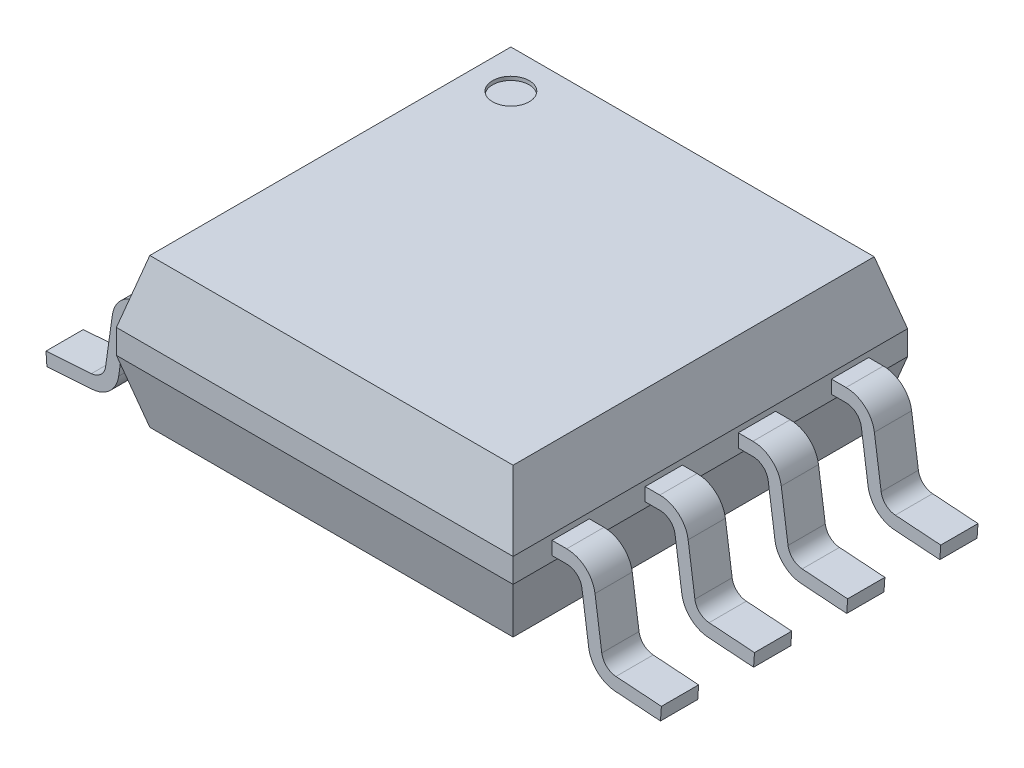
from build123d import *
from OCP.BRepFilletAPI import BRepFilletAPI_MakeChamfer

# Parameters (mm, degrees)
SKETCH1_W              = 5.41
SKETCH1_H              = 5.38
BASE_EXTRUDE_DEPTH     = 2.03
PIN_1_DEPTH            = 0.254
LPATTERN1_COUNT        = 4
LPATTERN1_PITCH        = 1.27
LPATTERN1_COPY_1_DEPTH = 0.254
LPATTERN1_COPY_2_DEPTH = 0.254
LPATTERN1_COPY_3_DEPTH = 0.254
TOP_CHAMFER_SIZE       = 0.85
TOP_CHAMFER_SIZE2      = 0.227756814
BOTTOM_CHAMFER_SIZE    = 0.85
BOTTOM_CHAMFER_SIZE2   = 0.227756814
SKETCH3_R              = 0.25
PIN1_HOL_DEPTH         = 0.05


with BuildPart() as part:
    # Sketch1 → Base-Extrude (new body)
    with BuildSketch(Plane(origin=(0, 0, 0), x_dir=(1, 0, 0), z_dir=(0, 1, 0))):
        Rectangle(SKETCH1_W, SKETCH1_H)
    extrude(amount=-BASE_EXTRUDE_DEPTH)

    # Sketch2 → PIN 1 (add, symmetric)
    with BuildSketch(Plane.XY.offset(-1.905)):
        with BuildLine():
            Line((-2.705, -0.925), (-2.905, -0.925))
            ThreePointArc((-2.905, -0.925), (-3.160863021, -1.020663264), (-3.291204547, -1.260722491))
            Line((-3.291204547, -1.260722491), (-3.38338656, -1.916631596))
            ThreePointArc((-3.38338656, -1.916631596), (-3.448123199, -2.040989522), (-3.576693995, -2.096893695))
            Line((-3.576693995, -2.096893695), (-4.196278083, -2.140219235))
            Line((-4.196278083, -2.140219235), (-4.183721917, -2.319780765))
            Line((-4.183721917, -2.319780765), (-3.56413783, -2.276455225))
            ThreePointArc((-3.56413783, -2.276455225), (-3.325363494, -2.172633189), (-3.205138308, -1.941682754))
            Line((-3.205138308, -1.941682754), (-3.112956294, -1.285773649))
            ThreePointArc((-3.112956294, -1.285773649), (-3.042772396, -1.156510988), (-2.905, -1.105))
            Line((-2.905, -1.105), (-2.705, -1.105))
            Line((-2.705, -1.105), (-2.705, -0.925))
        make_face()
    pin_1 = extrude(amount=PIN_1_DEPTH, both=True)

    # PIN 8: PIN 1 across plane
    add(pin_1.mirror(Plane(origin=(0, 0, 0), x_dir=(0, 0, 1), z_dir=(1, 0, 0))))

    # LPattern1: PIN 1 ×4
    with Locations(*[(0, 0, i * LPATTERN1_PITCH) for i in range(1, LPATTERN1_COUNT)]):
        add(pin_1)

    # LPattern1 copy 1 sketch → LPattern1 copy 1 (add, symmetric)
    with BuildSketch(Plane(origin=(0, 0, -0.635), x_dir=(-1, 0, 0), z_dir=(0, 0, 1))):
        with BuildLine():
            Line((-2.705, 0.925), (-2.905, 0.925))
            ThreePointArc((-2.905, 0.925), (-3.160863021, 1.020663264), (-3.291204547, 1.260722491))
            Line((-3.291204547, 1.260722491), (-3.38338656, 1.916631596))
            ThreePointArc((-3.38338656, 1.916631596), (-3.448123199, 2.040989522), (-3.576693995, 2.096893695))
            Line((-3.576693995, 2.096893695), (-4.196278083, 2.140219235))
            Line((-4.196278083, 2.140219235), (-4.183721917, 2.319780765))
            Line((-4.183721917, 2.319780765), (-3.56413783, 2.276455225))
            ThreePointArc((-3.56413783, 2.276455225), (-3.325363494, 2.172633189), (-3.205138308, 1.941682754))
            Line((-3.205138308, 1.941682754), (-3.112956294, 1.285773649))
            ThreePointArc((-3.112956294, 1.285773649), (-3.042772396, 1.156510988), (-2.905, 1.105))
            Line((-2.905, 1.105), (-2.705, 1.105))
            Line((-2.705, 1.105), (-2.705, 0.925))
        make_face()
    extrude(amount=LPATTERN1_COPY_1_DEPTH, both=True)

    # LPattern1 copy 2 sketch → LPattern1 copy 2 (add, symmetric)
    with BuildSketch(Plane(origin=(0, 0, 0.635), x_dir=(-1, 0, 0), z_dir=(0, 0, 1))):
        with BuildLine():
            Line((-2.705, 0.925), (-2.905, 0.925))
            ThreePointArc((-2.905, 0.925), (-3.160863021, 1.020663264), (-3.291204547, 1.260722491))
            Line((-3.291204547, 1.260722491), (-3.38338656, 1.916631596))
            ThreePointArc((-3.38338656, 1.916631596), (-3.448123199, 2.040989522), (-3.576693995, 2.096893695))
            Line((-3.576693995, 2.096893695), (-4.196278083, 2.140219235))
            Line((-4.196278083, 2.140219235), (-4.183721917, 2.319780765))
            Line((-4.183721917, 2.319780765), (-3.56413783, 2.276455225))
            ThreePointArc((-3.56413783, 2.276455225), (-3.325363494, 2.172633189), (-3.205138308, 1.941682754))
            Line((-3.205138308, 1.941682754), (-3.112956294, 1.285773649))
            ThreePointArc((-3.112956294, 1.285773649), (-3.042772396, 1.156510988), (-2.905, 1.105))
            Line((-2.905, 1.105), (-2.705, 1.105))
            Line((-2.705, 1.105), (-2.705, 0.925))
        make_face()
    extrude(amount=LPATTERN1_COPY_2_DEPTH, both=True)

    # LPattern1 copy 3 sketch → LPattern1 copy 3 (add, symmetric)
    with BuildSketch(Plane(origin=(0, 0, 1.905), x_dir=(-1, 0, 0), z_dir=(0, 0, 1))):
        with BuildLine():
            Line((-2.705, 0.925), (-2.905, 0.925))
            ThreePointArc((-2.905, 0.925), (-3.160863021, 1.020663264), (-3.291204547, 1.260722491))
            Line((-3.291204547, 1.260722491), (-3.38338656, 1.916631596))
            ThreePointArc((-3.38338656, 1.916631596), (-3.448123199, 2.040989522), (-3.576693995, 2.096893695))
            Line((-3.576693995, 2.096893695), (-4.196278083, 2.140219235))
            Line((-4.196278083, 2.140219235), (-4.183721917, 2.319780765))
            Line((-4.183721917, 2.319780765), (-3.56413783, 2.276455225))
            ThreePointArc((-3.56413783, 2.276455225), (-3.325363494, 2.172633189), (-3.205138308, 1.941682754))
            Line((-3.205138308, 1.941682754), (-3.112956294, 1.285773649))
            ThreePointArc((-3.112956294, 1.285773649), (-3.042772396, 1.156510988), (-2.905, 1.105))
            Line((-2.905, 1.105), (-2.705, 1.105))
            Line((-2.705, 1.105), (-2.705, 0.925))
        make_face()
    extrude(amount=LPATTERN1_COPY_3_DEPTH, both=True)

    # TOP CHAMFER: one chamfer whose edges measure the first distance from different faces: ONE call of the kernel's chamfer builder (chamfer() names one face for all edges)
    top_chamfer_edges_1 = [part.edges().sort_by_distance(p)[0] for p in [
        (0, 0, -2.69),
    ]]
    top_chamfer_side_1 = [part.faces().sort_by_distance(p)[0] for p in [
        (0, -1.015, -2.69),
    ]]
    top_chamfer_edges_2 = [part.edges().sort_by_distance(p)[0] for p in [
        (2.705, 0, 0),
    ]]
    top_chamfer_side_2 = [part.faces().sort_by_distance(p)[0] for p in [
        (2.705, -1.015, 0),
    ]]
    top_chamfer_edges_3 = [part.edges().sort_by_distance(p)[0] for p in [
        (0, 0, 2.69),
    ]]
    top_chamfer_side_3 = [part.faces().sort_by_distance(p)[0] for p in [
        (0, -1.015, 2.69),
    ]]
    top_chamfer_edges_4 = [part.edges().sort_by_distance(p)[0] for p in [
        (-2.705, 0, 0),
    ]]
    top_chamfer_side_4 = [part.faces().sort_by_distance(p)[0] for p in [
        (-2.705, -1.015, 0),
    ]]
    top_chamfer = BRepFilletAPI_MakeChamfer(part.part.solid().wrapped)
    for e in top_chamfer_edges_1:
        top_chamfer.Add(TOP_CHAMFER_SIZE, TOP_CHAMFER_SIZE2, e.wrapped, top_chamfer_side_1[0].wrapped)  # the first distance lies on this face
    for e in top_chamfer_edges_2:
        top_chamfer.Add(TOP_CHAMFER_SIZE, TOP_CHAMFER_SIZE2, e.wrapped, top_chamfer_side_2[0].wrapped)  # the first distance lies on this face
    for e in top_chamfer_edges_3:
        top_chamfer.Add(TOP_CHAMFER_SIZE, TOP_CHAMFER_SIZE2, e.wrapped, top_chamfer_side_3[0].wrapped)  # the first distance lies on this face
    for e in top_chamfer_edges_4:
        top_chamfer.Add(TOP_CHAMFER_SIZE, TOP_CHAMFER_SIZE2, e.wrapped, top_chamfer_side_4[0].wrapped)  # the first distance lies on this face
    add(Compound.cast(top_chamfer.Shape()), mode=Mode.REPLACE)

    # BOTTOM CHAMFER: one chamfer whose edges measure the first distance from different faces: ONE call of the kernel's chamfer builder (chamfer() names one face for all edges)
    bottom_chamfer_edges_1 = [part.edges().sort_by_distance(p)[0] for p in [
        (2.705, -2.03, 0),
    ]]
    bottom_chamfer_side_1 = [part.faces().sort_by_distance(p)[0] for p in [
        (2.705, -1.465983178, 0),
    ]]
    bottom_chamfer_edges_2 = [part.edges().sort_by_distance(p)[0] for p in [
        (0, -2.03, -2.69),
    ]]
    bottom_chamfer_side_2 = [part.faces().sort_by_distance(p)[0] for p in [
        (0, -1.44, -2.69),
    ]]
    bottom_chamfer_edges_3 = [part.edges().sort_by_distance(p)[0] for p in [
        (-2.705, -2.03, 0),
    ]]
    bottom_chamfer_side_3 = [part.faces().sort_by_distance(p)[0] for p in [
        (-2.705, -1.465983178, 0),
    ]]
    bottom_chamfer_edges_4 = [part.edges().sort_by_distance(p)[0] for p in [
        (0, -2.03, 2.69),
    ]]
    bottom_chamfer_side_4 = [part.faces().sort_by_distance(p)[0] for p in [
        (0, -1.44, 2.69),
    ]]
    bottom_chamfer = BRepFilletAPI_MakeChamfer(part.part.solid().wrapped)
    for e in bottom_chamfer_edges_1:
        bottom_chamfer.Add(BOTTOM_CHAMFER_SIZE, BOTTOM_CHAMFER_SIZE2, e.wrapped, bottom_chamfer_side_1[0].wrapped)  # the first distance lies on this face
    for e in bottom_chamfer_edges_2:
        bottom_chamfer.Add(BOTTOM_CHAMFER_SIZE, BOTTOM_CHAMFER_SIZE2, e.wrapped, bottom_chamfer_side_2[0].wrapped)  # the first distance lies on this face
    for e in bottom_chamfer_edges_3:
        bottom_chamfer.Add(BOTTOM_CHAMFER_SIZE, BOTTOM_CHAMFER_SIZE2, e.wrapped, bottom_chamfer_side_3[0].wrapped)  # the first distance lies on this face
    for e in bottom_chamfer_edges_4:
        bottom_chamfer.Add(BOTTOM_CHAMFER_SIZE, BOTTOM_CHAMFER_SIZE2, e.wrapped, bottom_chamfer_side_4[0].wrapped)  # the first distance lies on this face
    add(Compound.cast(bottom_chamfer.Shape()), mode=Mode.REPLACE)

    # Sketch3 → PIN1 HOL (cut)
    with BuildSketch(Plane(origin=(0, 0, 0), x_dir=(-1, 0, 0), z_dir=(0, 1, 0))):
        with Locations(Location((1.955, -1.94, 0), (0, 0, 90))):
            Circle(SKETCH3_R)
    extrude(amount=-PIN1_HOL_DEPTH, mode=Mode.SUBTRACT)


solid = part.part
